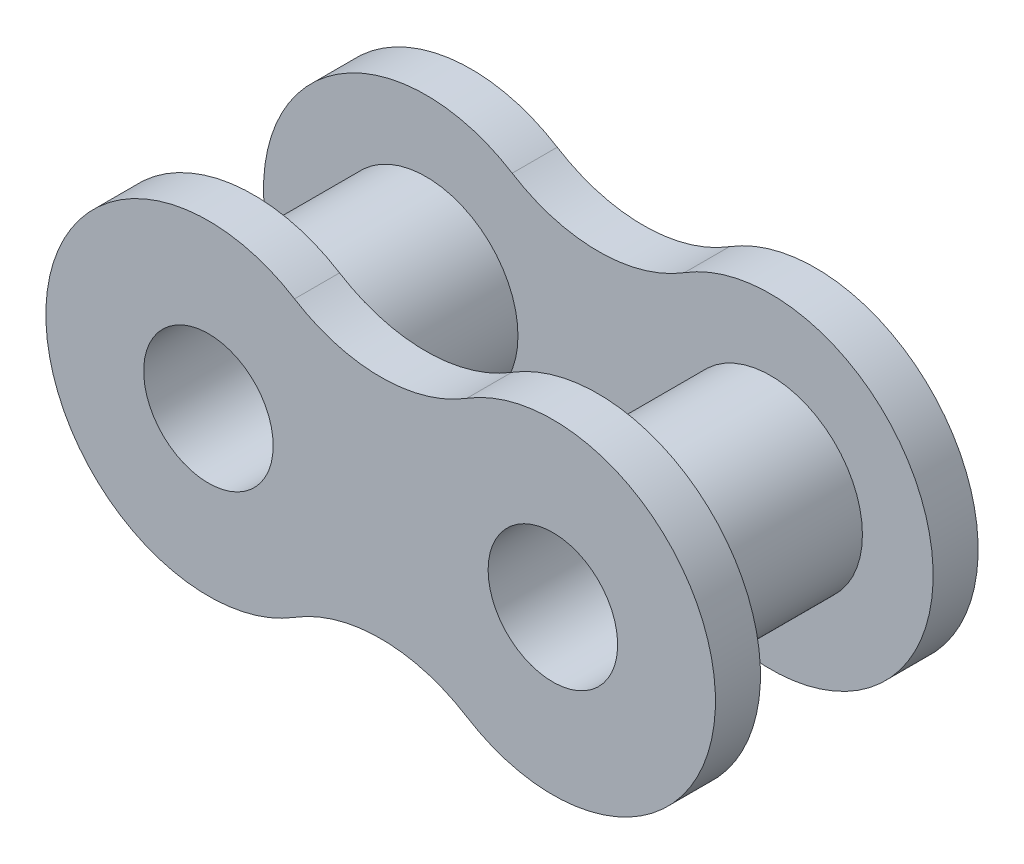
from build123d import *

# Parameters (mm, degrees)
SKETCH1_R             = 2.54
SKETCH1_R_2           = 1.7907
BOSS_EXTRUDE1_DEPTH   = 2.3876
BOSS_EXTRUDE1_2_DEPTH = 2.3876
SKETCH3_R             = 1.7907
BOSS_EXTRUDE2_DEPTH   = 1.2446


with BuildPart() as part:
    # Sketch1 → Boss-Extrude1 (new body, symmetric)
    with BuildSketch(Plane.XY):
        with Locations((-4.7625, 0)):
            Circle(SKETCH1_R)
        with Locations((-4.7625, 0)):
            Circle(SKETCH1_R_2, mode=Mode.SUBTRACT)
    extrude(amount=BOSS_EXTRUDE1_DEPTH, both=True)



with BuildPart() as body_2:
    # Sketch1 → Boss-Extrude1 2 (new body, symmetric)
    with BuildSketch(Plane.XY):
        with Locations((4.7625, 0)):
            Circle(SKETCH1_R)
        with Locations((4.7625, 0)):
            Circle(SKETCH1_R_2, mode=Mode.SUBTRACT)
    extrude(amount=BOSS_EXTRUDE1_2_DEPTH, both=True)


with BuildPart() as part_1:
    add(part.part)

    add(body_2.part)  # Boss-Extrude2 merges body 2
    # Sketch3 → Boss-Extrude2 (add)
    with BuildSketch(Plane.XY.offset(2.3876)):
        with BuildLine():
            ThreePointArc((-2.38125, 3.813379876), (-9.2583, 0), (-2.38125, -3.813379876))
            ThreePointArc((-2.38125, -3.813379876), (0, -3.130959752), (2.38125, -3.813379876))
            ThreePointArc((2.38125, -3.813379876), (9.2583, 0), (2.38125, 3.813379876))
            ThreePointArc((2.38125, 3.813379876), (0, 3.130959752), (-2.38125, 3.813379876))
        make_face()
        with Locations((-4.7625, 0)):
            Circle(SKETCH3_R, mode=Mode.SUBTRACT)
        with Locations((4.7625, 0)):
            Circle(SKETCH3_R, mode=Mode.SUBTRACT)
    boss_extrude2 = extrude(amount=BOSS_EXTRUDE2_DEPTH)

    # Mirror3: Boss-Extrude2 across plane
    add(boss_extrude2.mirror(Plane.XY))


solid = part_1.part
